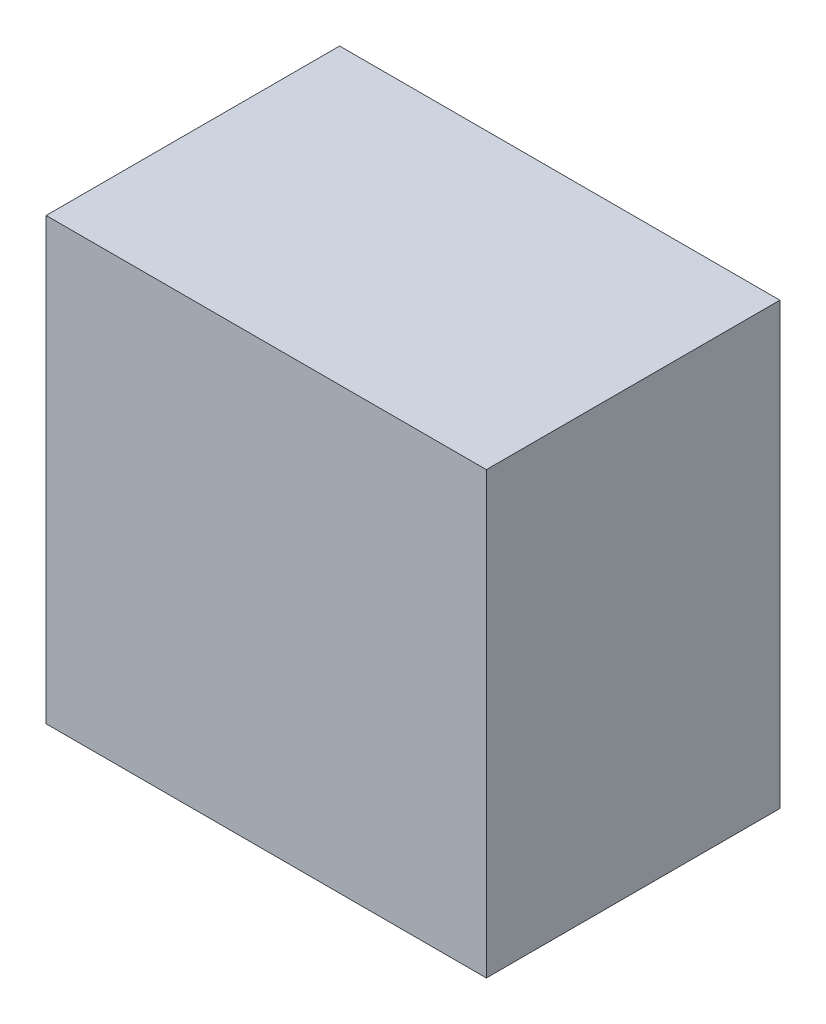
from build123d import *

# Parameters (mm, degrees)
SKETCH1_W           = 76.2
SKETCH1_H           = 50.8
BOSS_EXTRUDE1_DEPTH = 76.2


with BuildPart() as part:
    # Sketch1 → Boss-Extrude1 (new body)
    with BuildSketch(Plane(origin=(0, 0, 0), x_dir=(1, 0, 0), z_dir=(0, 1, 0))):
        with Locations((38.1, 25.4)):
            Rectangle(SKETCH1_W, SKETCH1_H)
    extrude(amount=BOSS_EXTRUDE1_DEPTH)


solid = part.part
